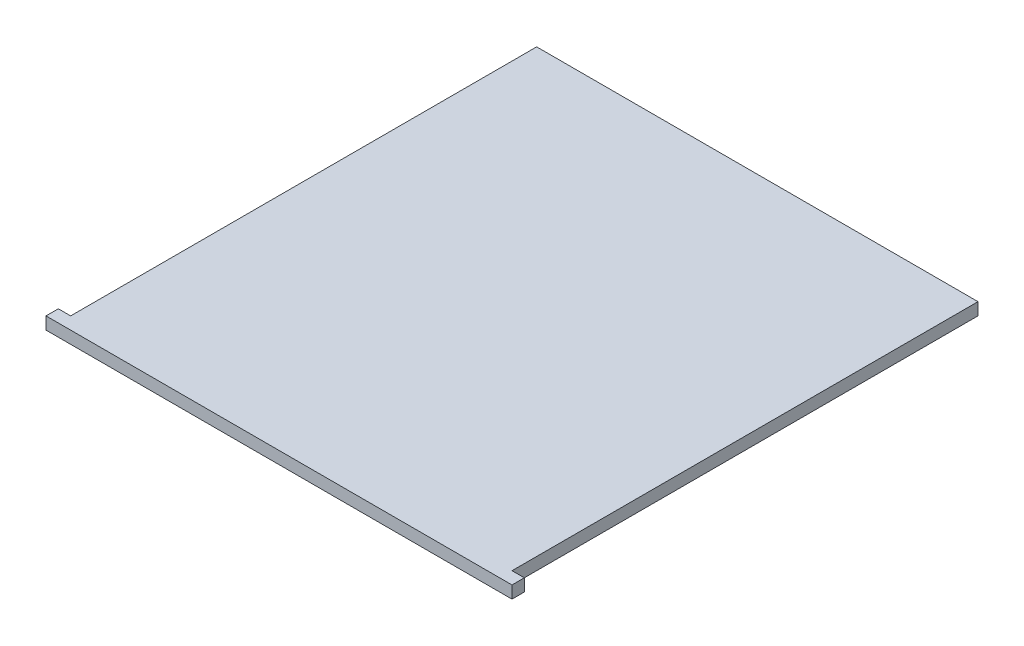
from build123d import *

# Parameters (mm, degrees)
SKETCH1_W           = 96.012
SKETCH1_H           = 98.552
BOSS_EXTRUDE1_DEPTH = 2.54
SKETCH2_W           = 2.54
SKETCH2_H           = 96.012
CUT_EXTRUDE1_DEPTH  = 2.54


with BuildPart() as part:
    # Sketch1 → Boss-Extrude1 (new body)
    with BuildSketch(Plane(origin=(0, 0, 0), x_dir=(1, 0, 0), z_dir=(0, 1, 0))):
        with Locations((48.006, 49.276)):
            Rectangle(SKETCH1_W, SKETCH1_H)
    extrude(amount=BOSS_EXTRUDE1_DEPTH)

    # Sketch2 → Cut-Extrude1 (cut)
    with BuildSketch(Plane(origin=(0, 2.54, 0), x_dir=(1, 0, 0), z_dir=(0, 1, 0))):
        with Locations((1.27, 50.546)):
            Rectangle(SKETCH2_W, SKETCH2_H)
        with Locations((94.742, 50.546)):
            Rectangle(SKETCH2_W, SKETCH2_H)
    extrude(amount=-CUT_EXTRUDE1_DEPTH, mode=Mode.SUBTRACT)


solid = part.part
